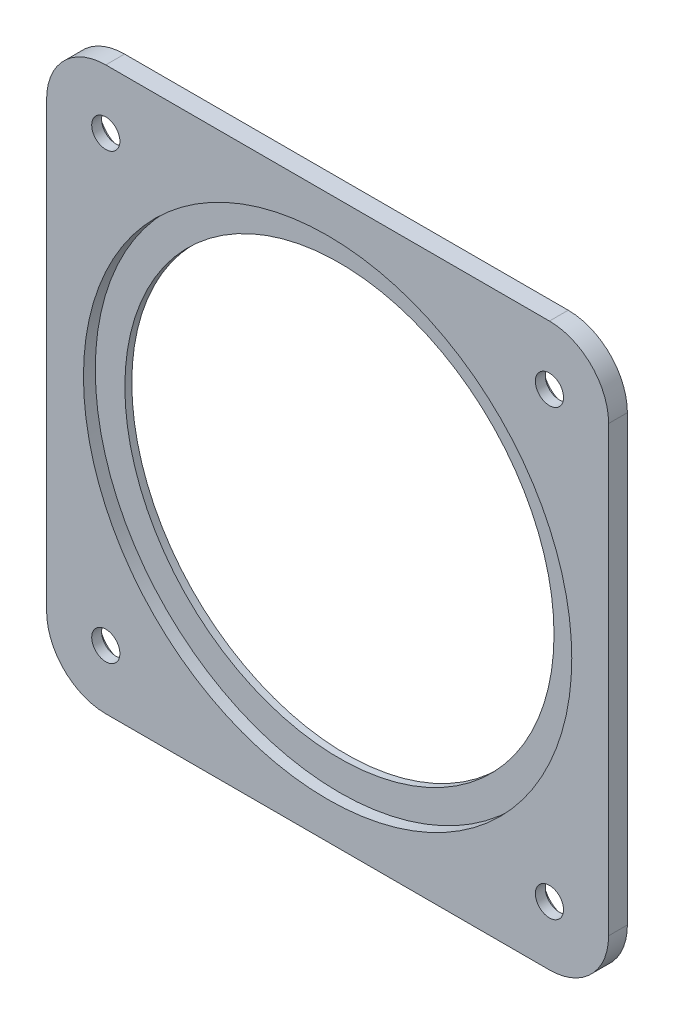
from build123d import *

# Parameters (mm, degrees)
SKETCH1_R           = 72.55
SKETCH1_R_2         = 4.7625
BOSS_EXTRUDE1_DEPTH = 6.35
SKETCH2_R           = 82.55
CUT_EXTRUDE1_DEPTH  = 4
SKETCH3_R           = 8.5
CUT_EXTRUDE2_DEPTH  = 3


with BuildPart() as part:
    # Sketch1 → Boss-Extrude1 (new body)
    with BuildSketch(Plane.XY):
        with BuildLine():
            Line((-75, -95), (75, -95))
            ThreePointArc((75, -95), (89.142135624, -89.142135624), (95, -75))
            Line((95, -75), (95, 75))
            ThreePointArc((95, 75), (89.142135624, 89.142135624), (75, 95))
            Line((75, 95), (-75, 95))
            ThreePointArc((-75, 95), (-89.142135624, 89.142135624), (-95, 75))
            Line((-95, 75), (-95, -75))
            ThreePointArc((-95, -75), (-89.142135624, -89.142135624), (-75, -95))
        make_face()
        Circle(SKETCH1_R, mode=Mode.SUBTRACT)
        with Locations((-75, 75)):
            Circle(SKETCH1_R_2, mode=Mode.SUBTRACT)
        with Locations((75, 75)):
            Circle(SKETCH1_R_2, mode=Mode.SUBTRACT)
        with Locations((75, -75)):
            Circle(SKETCH1_R_2, mode=Mode.SUBTRACT)
        with Locations((-75, -75)):
            Circle(SKETCH1_R_2, mode=Mode.SUBTRACT)
    extrude(amount=BOSS_EXTRUDE1_DEPTH)

    # Sketch2 → Cut-Extrude1 (cut)
    with BuildSketch(Plane.XY.offset(6.35)):
        Circle(SKETCH2_R)
    extrude(amount=-CUT_EXTRUDE1_DEPTH, mode=Mode.SUBTRACT)

    # Sketch3 → Cut-Extrude2 (cut)
    with BuildSketch(Plane(origin=(0, 0, 0), x_dir=(-1, 0, 0), z_dir=(0, 0, -1))):
        with Locations((-75, 75)):
            Circle(SKETCH3_R)
        with Locations((75, 75)):
            Circle(SKETCH3_R)
        with Locations((75, -75)):
            Circle(SKETCH3_R)
        with Locations((-75, -75)):
            Circle(SKETCH3_R)
    extrude(amount=-CUT_EXTRUDE2_DEPTH, mode=Mode.SUBTRACT)


solid = part.part
